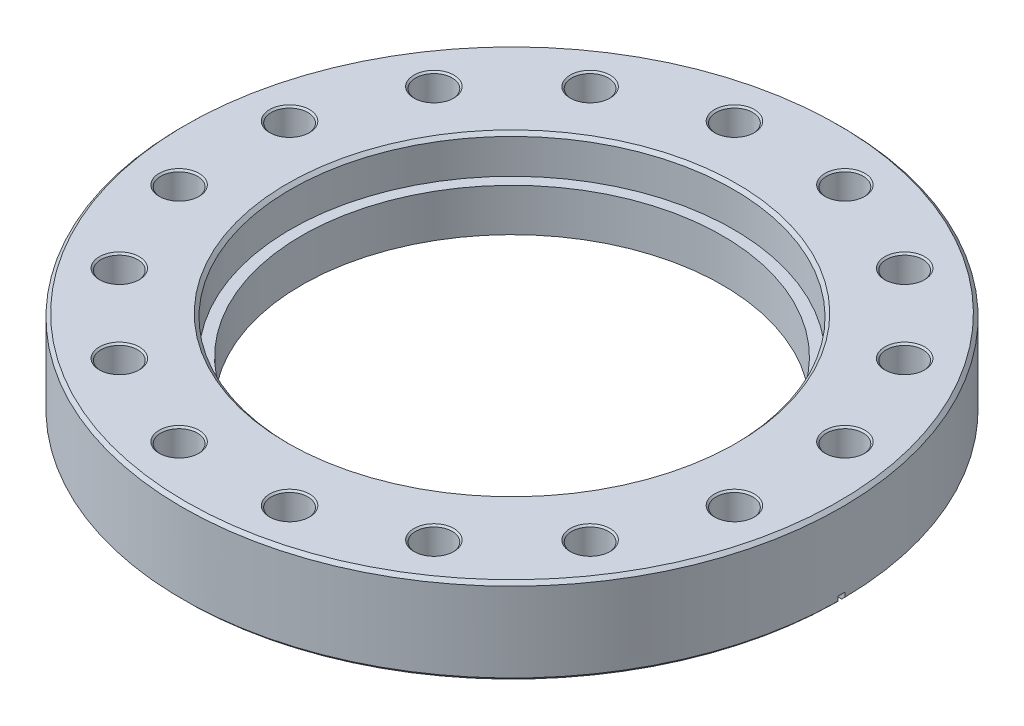
from build123d import *

# Parameters (mm, degrees)
SKETCH1_R                    = 75.819
SKETCH1_R_2                  = 48.387
BOSS_EXTRUDE1_DEPTH          = 19.812
SKETCH2_R                    = 50.927
CUT_EXTRUDE1_DEPTH           = 8.7122
CHAMFER1_SIZE                = 0.762
SKETCH4_R                    = 4.2164
CUT_EXTRUDE2_DEPTH           = 20.812
CHAMFER2_SIZE                = 0.381
CIRPATTERN1_COUNT            = 16
CHAMFER2_OF_CIRPATTERN1_SIZE = 0.381
CUT_EXTRUDE3_DEPTH           = 0.79375


with BuildPart() as part:
    # Sketch1 → Boss-Extrude1 (new body)
    with BuildSketch(Plane(origin=(0, 0, 0), x_dir=(1, 0, 0), z_dir=(0, 1, 0))):
        Circle(SKETCH1_R)
        Circle(SKETCH1_R_2, mode=Mode.SUBTRACT)
    extrude(amount=BOSS_EXTRUDE1_DEPTH)

    # Sketch2 → Cut-Extrude1 (cut)
    with BuildSketch(Plane(origin=(0, 19.812, 0), x_dir=(1, 0, 0), z_dir=(0, 1, 0))):
        Circle(SKETCH2_R)
    extrude(amount=-CUT_EXTRUDE1_DEPTH, mode=Mode.SUBTRACT)

    # Chamfer1
    chamfer1_edges = [part.edges().sort_by_distance(p)[0] for p in [
        (-50.927, 19.812, 0),
        (-75.819, 0, 0),
        (-75.819, 19.812, 0),
    ]]
    chamfer(chamfer1_edges, length=CHAMFER1_SIZE)

    # Sketch3 → Cut-Revolve1 (revolve, cut)
    with BuildSketch(Plane.XY):
        Polygon((-60.325, 0), (-60.325, 1.6256), (-57.658, 0.6604), (-57.658, 1.27), (0, 1.27), (0, 0), align=None)
    revolve(axis=Axis((0, 19.812, 0), (0, -1, 0)), mode=Mode.SUBTRACT)

    # Sketch4 → Cut-Extrude2 (cut, through all)
    with BuildSketch(Plane(origin=(0, 19.812, 0), x_dir=(1, 0, 0), z_dir=(0, 1, 0))):
        with Locations((-12.705374275, 63.874229857)):
            Circle(SKETCH4_R)
    cut_extrude2 = extrude(amount=-CUT_EXTRUDE2_DEPTH, mode=Mode.SUBTRACT)

    # Chamfer2
    chamfer2_edges = [part.edges().sort_by_distance(p)[0] for p in [
        (-16.921774275, 0, -63.874229857),
        (-16.921774275, 19.812, -63.874229857),
    ]]
    chamfer(chamfer2_edges, length=CHAMFER2_SIZE)

    # CirPattern1: Cut-Extrude2 ×16 about axis
    cirpattern1_axis = Axis((0, 0, 0), (0, 1, 0))
    for i in range(1, CIRPATTERN1_COUNT):
        add(cut_extrude2.rotate(cirpattern1_axis, i * 360 / CIRPATTERN1_COUNT), mode=Mode.SUBTRACT)

    # Chamfer2 of CirPattern1
    chamfer2_of_cirpattern1_edges = [part.edges().sort_by_distance(p)[0] for p in [
        (-40.077290428, 0, -52.536410959),
        (-40.077290428, 19.812, -52.536410959),
        (-57.131402415, 0, -33.200399735),
        (-57.131402415, 19.812, -33.200399735),
        (-65.487776282, 0, -8.809928615),
        (-65.487776282, 19.812, -8.809928615),
        (-63.874229857, 0, 16.921774275),
        (-63.874229857, 19.812, 16.921774275),
        (-52.536410959, 0, 40.077290428),
        (-52.536410959, 19.812, 40.077290428),
        (-33.200399735, 0, 57.131402415),
        (-33.200399735, 19.812, 57.131402415),
        (-8.809928615, 0, 65.487776282),
        (-8.809928615, 19.812, 65.487776282),
        (16.921774275, 0, 63.874229857),
        (16.921774275, 19.812, 63.874229857),
        (40.077290428, 0, 52.536410959),
        (40.077290428, 19.812, 52.536410959),
        (57.131402415, 0, 33.200399735),
        (57.131402415, 19.812, 33.200399735),
        (65.487776282, 0, 8.809928615),
        (65.487776282, 19.812, 8.809928615),
        (63.874229857, 0, -16.921774275),
        (63.874229857, 19.812, -16.921774275),
        (52.536410959, 0, -40.077290428),
        (52.536410959, 19.812, -40.077290428),
        (33.200399735, 0, -57.131402415),
        (33.200399735, 19.812, -57.131402415),
        (8.809928615, 0, -65.487776282),
        (8.809928615, 19.812, -65.487776282),
    ]]
    chamfer(chamfer2_of_cirpattern1_edges, length=CHAMFER2_OF_CIRPATTERN1_SIZE)

    # Sketch5 → Cut-Extrude3 (cut, symmetric)
    with BuildSketch(Plane.XY):
        Polygon((-59.310240326, 0.913241856), (-75.819, 1.778429289), (-75.819, -2.195076128), (-59.310240326, -2.195076128), align=None)
        Polygon((59.310240326, 0.913241856), (59.310240326, -2.195076128), (75.819, -2.195076128), (75.819, 1.778429289), align=None)
    extrude(amount=CUT_EXTRUDE3_DEPTH, both=True, mode=Mode.SUBTRACT)


solid = part.part
